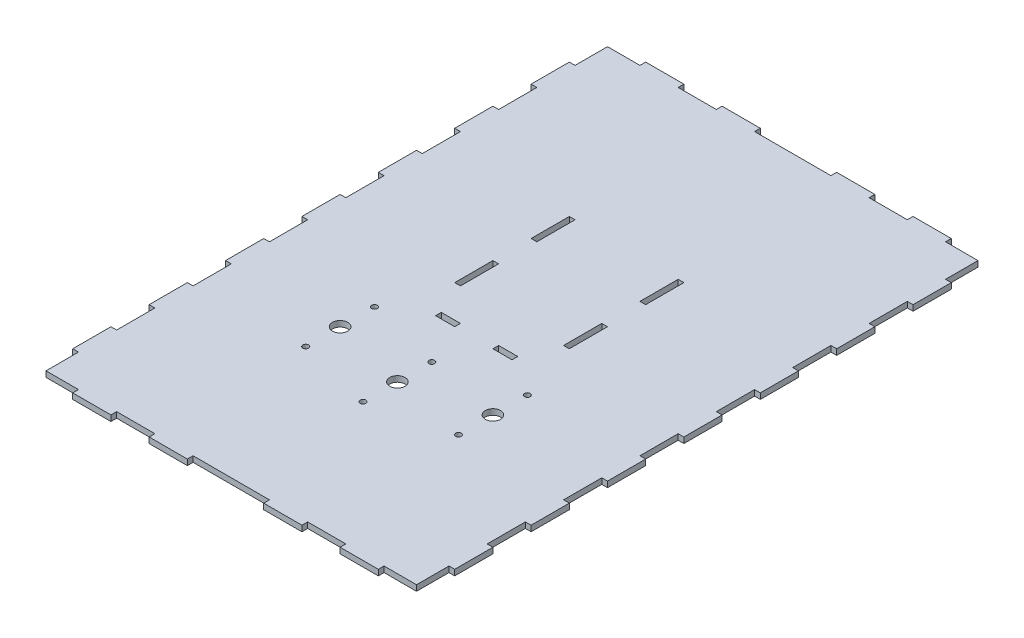
from build123d import *

# Parameters (mm, degrees)
SKETCH1_W           = 200
SKETCH1_H           = 300
BOSS_EXTRUDE1_DEPTH = 3
SKETCH2_W           = 3
SKETCH2_H           = 20
SKETCH2_W_2         = 10
SKETCH2_H_2         = 3
CUT_EXTRUDE1_DEPTH  = 3
SKETCH3_W           = 3
SKETCH3_H           = 20
SKETCH3_W_2         = 20
SKETCH3_H_2         = 3
SKETCH3_W_3         = 40
CUT_EXTRUDE2_DEPTH  = 3
SKETCH4_R           = 4
SKETCH4_R_2         = 1.5
CUT_EXTRUDE3_DEPTH  = 3


with BuildPart() as part:
    # Sketch1 → Boss-Extrude1 (new body)
    with BuildSketch(Plane(origin=(0, 0, 0), x_dir=(1, 0, 0), z_dir=(0, 1, 0))):
        Rectangle(SKETCH1_W, SKETCH1_H)
    extrude(amount=BOSS_EXTRUDE1_DEPTH)

    # Sketch2 → Cut-Extrude1 (cut)
    with BuildSketch(Plane(origin=(0, 3, 0), x_dir=(1, 0, 0), z_dir=(0, 1, 0))):
        with Locations((-28.5, 10)):
            Rectangle(SKETCH2_W, SKETCH2_H)
        with Locations((28.5, 10)):
            Rectangle(SKETCH2_W, SKETCH2_H)
        with Locations((15, -18.5)):
            Rectangle(SKETCH2_W_2, SKETCH2_H_2)
        with Locations((28.5, 50)):
            Rectangle(SKETCH2_W, SKETCH2_H)
        with Locations((-28.5, 50)):
            Rectangle(SKETCH2_W, SKETCH2_H)
        with Locations((-15, -18.5)):
            Rectangle(SKETCH2_W_2, SKETCH2_H_2)
    extrude(amount=-CUT_EXTRUDE1_DEPTH, mode=Mode.SUBTRACT)

    # Sketch3 → Cut-Extrude2 (cut)
    with BuildSketch(Plane(origin=(0, 3, 0), x_dir=(1, 0, 0), z_dir=(0, 1, 0))):
        Polygon((100, 130), (97, 130), (97, 147), (80, 147), (80, 150), (100, 150), align=None)
        with Locations((98.5, 100)):
            Rectangle(SKETCH3_W, SKETCH3_H)
        with Locations((98.5, 60)):
            Rectangle(SKETCH3_W, SKETCH3_H)
        Polygon((-100, 150), (-100, 130), (-97, 130), (-97, 147), (-80, 147), (-80, 150), align=None)
        Polygon((-100, -150), (-80, -150), (-80, -147), (-97, -147), (-97, -130), (-100, -130), align=None)
        Polygon((100, -150), (100, -130), (97, -130), (97, -147), (80, -147), (80, -150), align=None)
        with Locations((98.5, 20)):
            Rectangle(SKETCH3_W, SKETCH3_H)
        with Locations((98.5, -20)):
            Rectangle(SKETCH3_W, SKETCH3_H)
        with Locations((98.5, -60)):
            Rectangle(SKETCH3_W, SKETCH3_H)
        with Locations((98.5, -100)):
            Rectangle(SKETCH3_W, SKETCH3_H)
        with Locations((-98.5, 100)):
            Rectangle(SKETCH3_W, SKETCH3_H)
        with Locations((-98.5, 60)):
            Rectangle(SKETCH3_W, SKETCH3_H)
        with Locations((-98.5, 20)):
            Rectangle(SKETCH3_W, SKETCH3_H)
        with Locations((-98.5, -20)):
            Rectangle(SKETCH3_W, SKETCH3_H)
        with Locations((-98.5, -60)):
            Rectangle(SKETCH3_W, SKETCH3_H)
        with Locations((-98.5, -100)):
            Rectangle(SKETCH3_W, SKETCH3_H)
        with Locations((-50, 148.5)):
            Rectangle(SKETCH3_W_2, SKETCH3_H_2)
        with Locations((0, 148.5)):
            Rectangle(SKETCH3_W_3, SKETCH3_H_2)
        with Locations((50, 148.5)):
            Rectangle(SKETCH3_W_2, SKETCH3_H_2)
        with Locations((50, -148.5)):
            Rectangle(SKETCH3_W_2, SKETCH3_H_2)
        with Locations((0, -148.5)):
            Rectangle(SKETCH3_W_3, SKETCH3_H_2)
        with Locations((-50, -148.5)):
            Rectangle(SKETCH3_W_2, SKETCH3_H_2)
    extrude(amount=-CUT_EXTRUDE2_DEPTH, mode=Mode.SUBTRACT)

    # Sketch4 → Cut-Extrude3 (cut)
    with BuildSketch(Plane(origin=(0, 3, 0), x_dir=(1, 0, 0), z_dir=(0, 1, 0))):
        with Locations((0, -60)):
            Circle(SKETCH4_R)
        with Locations((40, -50)):
            Circle(SKETCH4_R)
        with Locations((-40, -50)):
            Circle(SKETCH4_R)
        with Locations((40, -32)):
            Circle(SKETCH4_R_2)
        with Locations((40, -68)):
            Circle(SKETCH4_R_2)
        with Locations((0, -42)):
            Circle(SKETCH4_R_2)
        with Locations((0, -78)):
            Circle(SKETCH4_R_2)
        with Locations((-40, -32)):
            Circle(SKETCH4_R_2)
        with Locations((-40, -68)):
            Circle(SKETCH4_R_2)
    extrude(amount=-CUT_EXTRUDE3_DEPTH, mode=Mode.SUBTRACT)


solid = part.part
